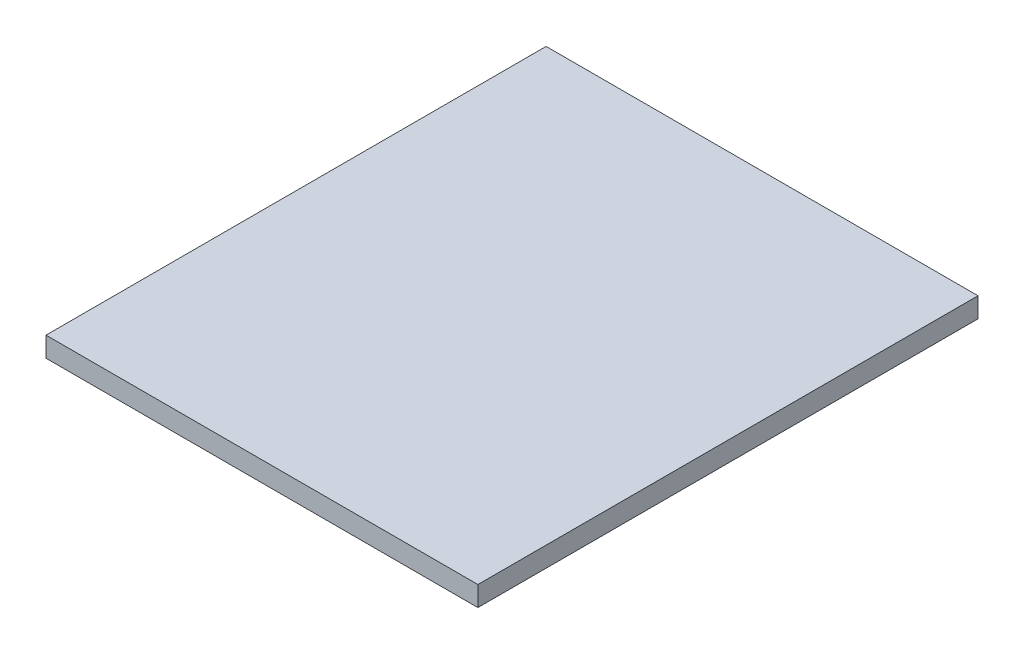
from build123d import *

# Parameters (mm, degrees)
SKETCH3_W           = 500
SKETCH3_H           = 20
BOSS_EXTRUDE3_DEPTH = 215.9


with BuildPart() as part:
    # Sketch3 → Boss-Extrude3 (new, symmetric)
    with BuildSketch(Plane(origin=(0, 0, 0), x_dir=(0, 0, -1), z_dir=(1, 0, 0))):
        with Locations((-250, -10)):
            Rectangle(SKETCH3_W, SKETCH3_H)
    extrude(amount=BOSS_EXTRUDE3_DEPTH, both=True)


solid = part.part
